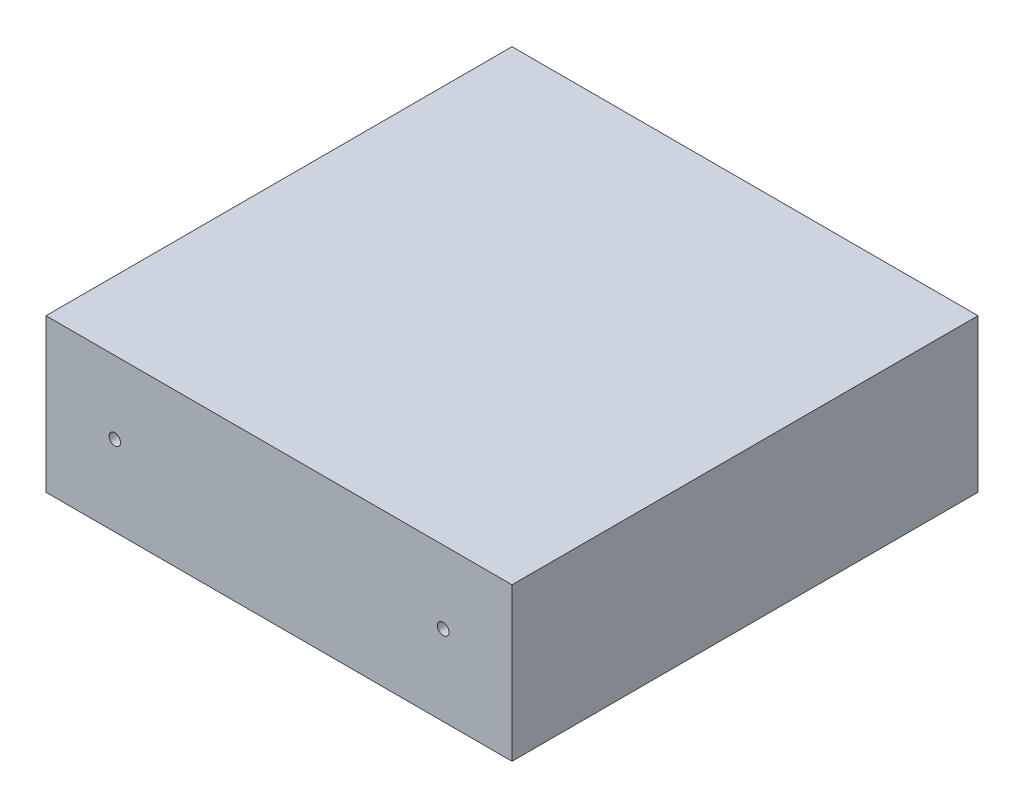
from build123d import *

# Parameters (mm, degrees)
SKETCH1_W           = 406.4
SKETCH1_H           = 406.4
BOSS_EXTRUDE1_DEPTH = 133.35
SKETCH2_R           = 5
CUT_EXTRUDE1_DEPTH  = 407.4


with BuildPart() as part:
    # Sketch1 → Boss-Extrude1 (new body)
    with BuildSketch(Plane(origin=(0, 0, 0), x_dir=(1, 0, 0), z_dir=(0, 1, 0))):
        with Locations((203.2, 203.2)):
            Rectangle(SKETCH1_W, SKETCH1_H)
    extrude(amount=BOSS_EXTRUDE1_DEPTH)

    # Sketch2 → Cut-Extrude1 (cut, through all)
    with BuildSketch(Plane.XY):
        with Locations((60, 70)):
            Circle(SKETCH2_R)
        with Locations((346.4, 70)):
            Circle(SKETCH2_R)
    extrude(amount=-CUT_EXTRUDE1_DEPTH, mode=Mode.SUBTRACT)


solid = part.part
